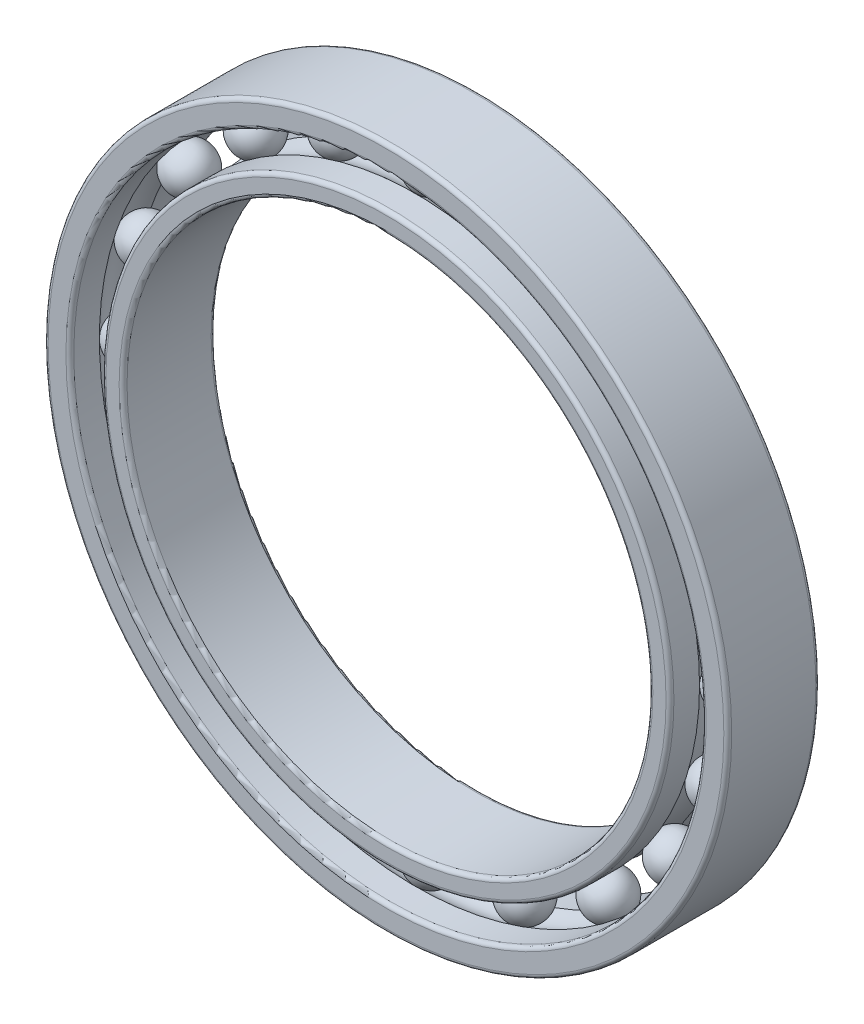
from build123d import *

# Parameters (mm, degrees)
KREISMUSTER4_COUNT = 20
VERRUNDUNG1_R      = 0.3
VERRUNDUNG2_R      = 0.3


with BuildPart() as part:
    # Skizze1 → Rotation1 (revolve)
    with BuildSketch(Plane(origin=(0, 0, 0), x_dir=(0, 0, -1), z_dir=(1, 0, 0))):
        with BuildLine():
            Line((3.5, 26), (-3.5, 26))
            Line((-3.5, 26), (-3.5, 24.05))
            Line((-3.5, 24.05), (-1.252195572, 24.05))
            ThreePointArc((-1.252195572, 24.05), (0, 24.5775), (1.252195572, 24.05))
            Line((1.252195572, 24.05), (3.5, 24.05))
            Line((3.5, 24.05), (3.5, 26))
        make_face()
        with BuildLine():
            ThreePointArc((1.252195572, 21.605), (0, 21.0775), (-1.252195572, 21.605))
            Line((-1.252195572, 21.605), (-3.5, 21.605))
            Line((-3.5, 21.605), (-3.5, 20))
            Line((-3.5, 20), (3.5, 20))
            Line((3.5, 20), (3.5, 21.605))
            Line((3.5, 21.605), (1.252195572, 21.605))
        make_face()
    revolve(axis=Axis((0, 0, 0), (0, 0, -1)))

    # Verrundung1
    verrundung1_edges = [part.edges().sort_by_distance(p)[0] for p in [
        (0, -24.05, -3.5),
        (0, -24.05, 3.5),
        (0, -26, -3.5),
        (0, -26, 3.5),
    ]]
    fillet(verrundung1_edges, radius=VERRUNDUNG1_R)

    # Verrundung2
    verrundung2_edges = [part.edges().sort_by_distance(p)[0] for p in [
        (0, -21.605, -3.5),
        (0, -20, -3.5),
        (0, -21.605, 3.5),
        (0, -20, 3.5),
    ]]
    fillet(verrundung2_edges, radius=VERRUNDUNG2_R)


with BuildPart() as body_2:
    # Skizze1_5 → Rotation3 (revolve)
    with BuildSketch(Plane(origin=(0, 0, 0), x_dir=(0, 0, -1), z_dir=(1, 0, 0))):
        with BuildLine():
            ThreePointArc((1.252195572, 24.05), (0, 24.5775), (-1.252195572, 24.05))
            ThreePointArc((-1.252195572, 24.05), (-1.620777938, 23.487483996), (-1.75, 22.8275))
            Line((-1.75, 22.8275), (1.75, 22.8275))
            ThreePointArc((1.75, 22.8275), (1.620777938, 23.487483996), (1.252195572, 24.05))
        make_face()
    revolve(axis=Axis((0, 22.8275, 1.75), (0, 0, -1)))


with BuildPart() as kreismuster4_1:
    # Kreismuster4: pattern copy
    add(body_2.part.rotate(Axis((0, 0, -3.5), (0, 0, 1)), 1 * 360 / KREISMUSTER4_COUNT))


with BuildPart() as kreismuster4_2:
    # Kreismuster4: pattern copy
    add(body_2.part.rotate(Axis((0, 0, -3.5), (0, 0, 1)), 2 * 360 / KREISMUSTER4_COUNT))


with BuildPart() as kreismuster4_3:
    # Kreismuster4: pattern copy
    add(body_2.part.rotate(Axis((0, 0, -3.5), (0, 0, 1)), 3 * 360 / KREISMUSTER4_COUNT))


with BuildPart() as kreismuster4_4:
    # Kreismuster4: pattern copy
    add(body_2.part.rotate(Axis((0, 0, -3.5), (0, 0, 1)), 4 * 360 / KREISMUSTER4_COUNT))


with BuildPart() as kreismuster4_5:
    # Kreismuster4: pattern copy
    add(body_2.part.rotate(Axis((0, 0, -3.5), (0, 0, 1)), 5 * 360 / KREISMUSTER4_COUNT))


with BuildPart() as kreismuster4_6:
    # Kreismuster4: pattern copy
    add(body_2.part.rotate(Axis((0, 0, -3.5), (0, 0, 1)), 6 * 360 / KREISMUSTER4_COUNT))


with BuildPart() as kreismuster4_7:
    # Kreismuster4: pattern copy
    add(body_2.part.rotate(Axis((0, 0, -3.5), (0, 0, 1)), 7 * 360 / KREISMUSTER4_COUNT))


with BuildPart() as kreismuster4_8:
    # Kreismuster4: pattern copy
    add(body_2.part.rotate(Axis((0, 0, -3.5), (0, 0, 1)), 8 * 360 / KREISMUSTER4_COUNT))


with BuildPart() as kreismuster4_9:
    # Kreismuster4: pattern copy
    add(body_2.part.rotate(Axis((0, 0, -3.5), (0, 0, 1)), 9 * 360 / KREISMUSTER4_COUNT))


with BuildPart() as kreismuster4_10:
    # Kreismuster4: pattern copy
    add(body_2.part.rotate(Axis((0, 0, -3.5), (0, 0, 1)), 10 * 360 / KREISMUSTER4_COUNT))


with BuildPart() as kreismuster4_11:
    # Kreismuster4: pattern copy
    add(body_2.part.rotate(Axis((0, 0, -3.5), (0, 0, 1)), 11 * 360 / KREISMUSTER4_COUNT))


with BuildPart() as kreismuster4_12:
    # Kreismuster4: pattern copy
    add(body_2.part.rotate(Axis((0, 0, -3.5), (0, 0, 1)), 12 * 360 / KREISMUSTER4_COUNT))


with BuildPart() as kreismuster4_13:
    # Kreismuster4: pattern copy
    add(body_2.part.rotate(Axis((0, 0, -3.5), (0, 0, 1)), 13 * 360 / KREISMUSTER4_COUNT))


with BuildPart() as kreismuster4_14:
    # Kreismuster4: pattern copy
    add(body_2.part.rotate(Axis((0, 0, -3.5), (0, 0, 1)), 14 * 360 / KREISMUSTER4_COUNT))


with BuildPart() as kreismuster4_15:
    # Kreismuster4: pattern copy
    add(body_2.part.rotate(Axis((0, 0, -3.5), (0, 0, 1)), 15 * 360 / KREISMUSTER4_COUNT))


with BuildPart() as kreismuster4_16:
    # Kreismuster4: pattern copy
    add(body_2.part.rotate(Axis((0, 0, -3.5), (0, 0, 1)), 16 * 360 / KREISMUSTER4_COUNT))


with BuildPart() as kreismuster4_17:
    # Kreismuster4: pattern copy
    add(body_2.part.rotate(Axis((0, 0, -3.5), (0, 0, 1)), 17 * 360 / KREISMUSTER4_COUNT))


with BuildPart() as kreismuster4_18:
    # Kreismuster4: pattern copy
    add(body_2.part.rotate(Axis((0, 0, -3.5), (0, 0, 1)), 18 * 360 / KREISMUSTER4_COUNT))


with BuildPart() as kreismuster4_19:
    # Kreismuster4: pattern copy
    add(body_2.part.rotate(Axis((0, 0, -3.5), (0, 0, 1)), 19 * 360 / KREISMUSTER4_COUNT))


solid = Compound([part.part, body_2.part, kreismuster4_1.part, kreismuster4_2.part, kreismuster4_3.part, kreismuster4_4.part, kreismuster4_5.part, kreismuster4_6.part, kreismuster4_7.part, kreismuster4_8.part, kreismuster4_9.part, kreismuster4_10.part, kreismuster4_11.part, kreismuster4_12.part, kreismuster4_13.part, kreismuster4_14.part, kreismuster4_15.part, kreismuster4_16.part, kreismuster4_17.part, kreismuster4_18.part, kreismuster4_19.part])
